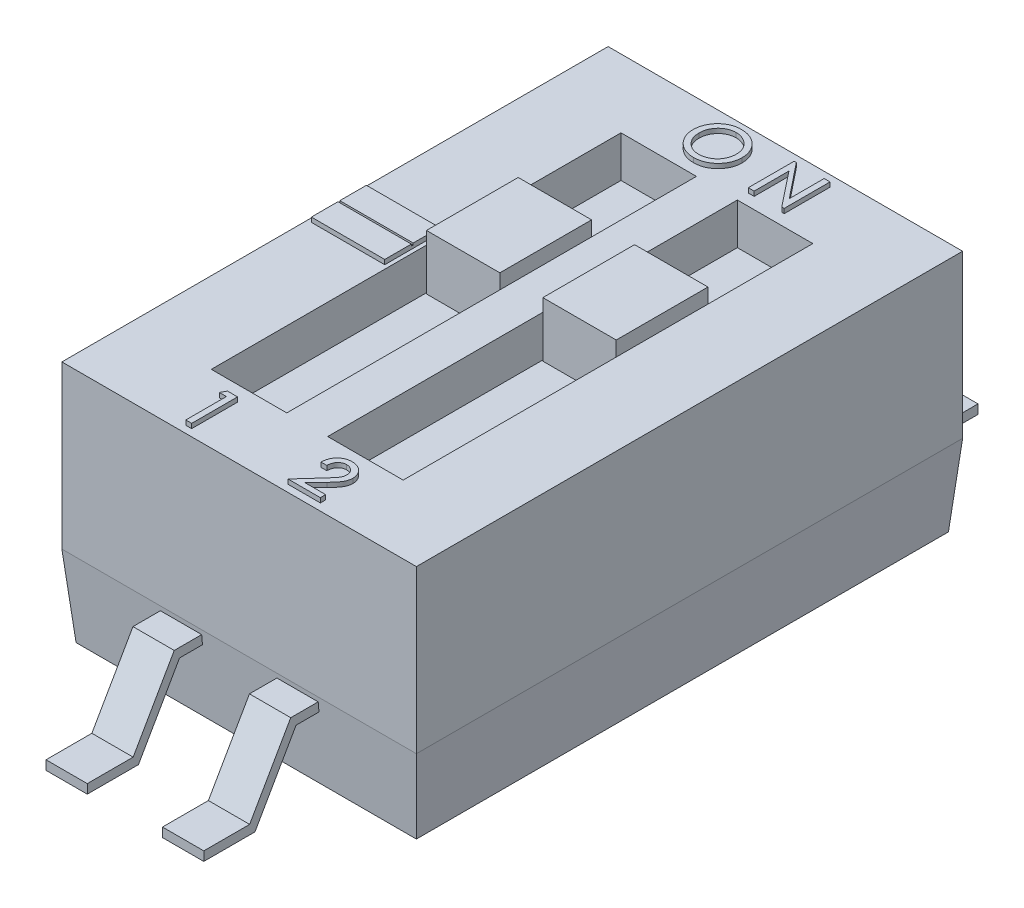
from build123d import *

# Parameters (mm, degrees)
SKETCH1_W            = 3.71
SKETCH1_H            = 5.8
BOSS_EXTRUDE1_DEPTH  = 0.883333333
BOSS_EXTRUDE1_TAPER  = -5
SKETCH2_W            = 3.864563306
SKETCH2_H            = 5.954563306
BOSS_EXTRUDE2_DEPTH  = 1.76666666
EXTRUDE_THIN1_START  = 1.3
EXTRUDE_THIN1_DEPTH  = 0.225
LPATTERN1_COUNT      = 2
LPATTERN1_PITCH      = 1.27
MIRROR1_START        = 1.3
MIRROR1_COPY_1_DEPTH = 0.225
SKETCH4_W            = 0.822718347
SKETCH4_H            = 4.46592248
CUT_EXTRUDE1_DEPTH   = 0.45
SKETCH7_W            = 0.8
SKETCH7_H            = 1
BOSS_EXTRUDE3_DEPTH  = 0.6
BOSS_EXTRUDE4_DEPTH  = 0.05
SKETCH10_W           = 0.803291247
SKETCH10_H           = 0.02
CUT_EXTRUDE2_DEPTH   = 0.02


with BuildPart() as part:
    # Sketch1 → Boss-Extrude1 (new body)
    with BuildSketch(Plane(origin=(0, 0, 0), x_dir=(1, 0, 0), z_dir=(0, 1, 0))):
        with Locations((1.855, 2.9)):
            Rectangle(SKETCH1_W, SKETCH1_H)
    extrude(amount=BOSS_EXTRUDE1_DEPTH, taper=BOSS_EXTRUDE1_TAPER)

    # Sketch2 → Boss-Extrude2 (add)
    with BuildSketch(Plane(origin=(0, 0.883333333, 0), x_dir=(1, 0, 0), z_dir=(0, 1, 0))):
        with Locations((1.855, 2.9)):
            Rectangle(SKETCH2_W, SKETCH2_H)
    extrude(amount=BOSS_EXTRUDE2_DEPTH)

    # Sketch3 → Extrude-Thin1 (add, symmetric)
    with BuildSketch(Plane(origin=(3.787281653, 2.093388662, 0), x_dir=(0, 0, -1), z_dir=(-1, 0, 0)).offset(EXTRUDE_THIN1_START)):
        Polygon((5.860743349, 1.260055329), (6.17213084, 1.260055329), (6.620020803, 2.043388662), (7.12, 2.043388662), (7.12, 2.143388662), (6.562005971, 2.143388662), (6.114116009, 1.360055329), (5.860743349, 1.360055329), align=None)
    extrude_thin1 = extrude(amount=EXTRUDE_THIN1_DEPTH, both=True)

    # LPattern1: Extrude-Thin1 ×2
    with Locations(*[(-i * LPATTERN1_PITCH, 0, 0) for i in range(1, LPATTERN1_COUNT)]):
        add(extrude_thin1)

    # Mirror1: Extrude-Thin1 across plane
    add(extrude_thin1.mirror(Plane.XY.offset(-2.9)))

    # Mirror1 copy 1 sketch → Mirror1 copy 1 (add, symmetric)
    with BuildSketch(Plane(origin=(2.517281653, 2.093388662, -5.8), x_dir=(0, 0, 1), z_dir=(-1, 0, 0)).offset(MIRROR1_START)):
        Polygon((5.860743349, -1.260055329), (6.17213084, -1.260055329), (6.620020803, -2.043388662), (7.12, -2.043388662), (7.12, -2.143388662), (6.562005971, -2.143388662), (6.114116009, -1.360055329), (5.860743349, -1.360055329), align=None)
    extrude(amount=MIRROR1_COPY_1_DEPTH, both=True)

    # Sketch4 → Cut-Extrude1 (cut)
    with BuildSketch(Plane(origin=(0, 2.649999993, 0), x_dir=(1, 0, 0), z_dir=(0, 1, 0))):
        with Locations((1.218640827, 2.9)):
            Rectangle(SKETCH4_W, SKETCH4_H)
        with Locations((2.487281653, 2.9)):
            Rectangle(SKETCH4_W, SKETCH4_H)
    extrude(amount=-CUT_EXTRUDE1_DEPTH, mode=Mode.SUBTRACT)

    # Sketch7 → Boss-Extrude3 (add)
    with BuildSketch(Plane(origin=(0, 2.199999993, 0), x_dir=(1, 0, 0), z_dir=(0, 1, 0))):
        with Locations((1.218640826, 3.501198468)):
            Rectangle(SKETCH7_W, SKETCH7_H)
        with Locations((2.487281653, 3.501198468)):
            Rectangle(SKETCH7_W, SKETCH7_H)
    extrude(amount=BOSS_EXTRUDE3_DEPTH)

    # Sketch9 → Boss-Extrude4 (add)
    with BuildSketch(Plane(origin=(0, 2.649999993, 0), x_dir=(1, 0, 0), z_dir=(0, 1, 0))):
        Polygon((0.365, 3.2), (-0.035, 3.2), (-0.035, 2.6), (0.765, 2.6), (0.765, 3.2), align=None)
        with BuildLine():
            add(Edge.make_bspline(
                [(1.479663964, 5.771654884), (1.489257845, 5.771433396), (1.508114811, 5.770998055), (1.535777861, 5.767286325), (1.562195202, 5.761348327), (1.587327869, 5.752866749), (1.611192828, 5.741999278), (1.633827731, 5.728725029), (1.655165361, 5.71300379), (1.674944838, 5.695037092), (1.692912044, 5.675465931), (1.708834839, 5.654777937), (1.722056925, 5.632881513), (1.733109928, 5.610093514), (1.741473317, 5.586202533), (1.747669692, 5.561410989), (1.75132416, 5.535552796), (1.75177232, 5.517960449), (1.751999701, 5.509034692)],
                knots=[0, 0, 0, 0, 2.8771e-05, 5.655e-05, 8.3569e-05, 0.00010989, 0.000135976, 0.000162104, 0.000188468, 0.000215344, 0.000242139, 0.000268081, 0.000293522, 0.000318743, 0.000343928, 0.000369314, 0.000395306, 0.000422076, 0.000422076, 0.000422076, 0.000422076], degree=3))
            add(Edge.make_bspline(
                [(1.751999701, 5.509034692), (1.751776692, 5.500174582), (1.751337183, 5.482712978), (1.747612498, 5.457012356), (1.741607695, 5.432250852), (1.733198418, 5.408380247), (1.722167038, 5.385582617), (1.708878823, 5.363666692), (1.693051826, 5.342841811), (1.675151667, 5.32313365), (1.655480601, 5.305102448), (1.634359091, 5.289267014), (1.612043342, 5.275938627), (1.588644525, 5.264843355), (1.563971225, 5.256513354), (1.538207672, 5.25033631), (1.511252453, 5.246686748), (1.492896153, 5.24624055), (1.483570214, 5.246013859)],
                knots=[0, 0, 0, 0, 2.657e-05, 5.2364e-05, 7.7726e-05, 0.00010291, 0.000128132, 0.000153572, 0.000179674, 0.000206476, 0.000233345, 0.000259607, 0.000285528, 0.000311202, 0.000337143, 0.000363502, 0.000390586, 0.000418557, 0.000418557, 0.000418557, 0.000418557], degree=3))
            add(Edge.make_bspline(
                [(1.483570214, 5.246013859), (1.474476052, 5.246233696), (1.456581448, 5.24666627), (1.430329778, 5.250413333), (1.405143496, 5.256254742), (1.381055145, 5.264649956), (1.358026463, 5.275357899), (1.336188652, 5.288640852), (1.315348755, 5.30411141), (1.295903175, 5.321834298), (1.278156443, 5.341241912), (1.262589861, 5.361900578), (1.249350395, 5.383547494), (1.238580322, 5.406207419), (1.23019009, 5.429901874), (1.224369717, 5.454625163), (1.220601755, 5.48030682), (1.220168337, 5.497769958), (1.219948419, 5.506630846)],
                knots=[0, 0, 0, 0, 2.727e-05, 5.3659e-05, 7.9387e-05, 0.000104728, 0.000130045, 0.000155433, 0.000181275, 0.000207794, 0.000234238, 0.00026006, 0.000285277, 0.000310231, 0.000335194, 0.000360532, 0.000386326, 0.000412896, 0.000412896, 0.000412896, 0.000412896], degree=3))
            add(Edge.make_bspline(
                [(1.219948419, 5.506630846), (1.220024725, 5.512578397), (1.220176375, 5.52439847), (1.222004794, 5.541950438), (1.224652588, 5.559222042), (1.228467221, 5.576155156), (1.23338749, 5.592752794), (1.239451934, 5.608980085), (1.246397915, 5.624974183), (1.254682806, 5.640417607), (1.263677877, 5.655400044), (1.273673358, 5.669519096), (1.284246363, 5.682946687), (1.295842055, 5.695324371), (1.30807273, 5.707015016), (1.321138279, 5.717838228), (1.334958582, 5.727891801), (1.349593212, 5.736951848), (1.364681536, 5.74514601), (1.380235362, 5.752177703), (1.396043443, 5.758212855), (1.412179821, 5.763104401), (1.428601646, 5.766966121), (1.445344758, 5.769595743), (1.462395819, 5.771427788), (1.47388315, 5.77157886), (1.479663964, 5.771654884)],
                knots=[0, 0, 0, 0, 1.7836e-05, 3.5446e-05, 5.2885e-05, 7.0234e-05, 8.7474e-05, 0.000104777, 0.000122178, 0.000139741, 0.000157314, 0.00017457, 0.000191605, 0.000208544, 0.000225405, 0.000242333, 0.000259403, 0.000276634, 0.000293932, 0.000310876, 0.000327804, 0.00034466, 0.000361424, 0.000378368, 0.00039548, 0.000412815, 0.000412815, 0.000412815, 0.000412815], degree=3))
        make_face()
        with BuildLine():
            add(Edge.make_bspline(
                [(1.481767329, 5.713962577), (1.477556873, 5.713895927), (1.469182182, 5.71376336), (1.456706127, 5.712375722), (1.444359264, 5.710291289), (1.432120207, 5.707359756), (1.419978865, 5.703696746), (1.40803974, 5.699010727), (1.396187477, 5.693649112), (1.384633487, 5.687293585), (1.373370275, 5.680394675), (1.362716929, 5.672692959), (1.352551182, 5.664506348), (1.343019529, 5.655559036), (1.334139864, 5.645968161), (1.325862878, 5.635749499), (1.318125396, 5.624938392), (1.311096856, 5.613459905), (1.304605208, 5.601551603), (1.299140706, 5.589136394), (1.294511867, 5.576346372), (1.29071283, 5.563195005), (1.287669032, 5.549656276), (1.285632562, 5.535725166), (1.284240524, 5.521416076), (1.284114809, 5.511742461), (1.284050983, 5.506831166)],
                knots=[0, 0, 0, 0, 1.2627e-05, 2.5114e-05, 3.7612e-05, 5.0172e-05, 6.2846e-05, 7.5624e-05, 8.8622e-05, 0.000101844, 0.000115157, 0.000128221, 0.000141252, 0.00015429, 0.000167402, 0.000180433, 0.000193718, 0.000207255, 0.000220788, 0.000234375, 0.000247904, 0.000261566, 0.000275417, 0.000289498, 0.00030378, 0.000318509, 0.000318509, 0.000318509, 0.000318509], degree=3))
            add(Edge.make_bspline(
                [(1.284050983, 5.506831166), (1.284206025, 5.499676188), (1.284510118, 5.485642709), (1.287442798, 5.465058319), (1.29198946, 5.445388442), (1.298425049, 5.426652988), (1.306711554, 5.408857624), (1.316853606, 5.392007493), (1.328868208, 5.37606037), (1.342612023, 5.361322703), (1.357511695, 5.347856567), (1.373315803, 5.336122329), (1.38966252, 5.325975478), (1.406814183, 5.317842465), (1.424602673, 5.31150428), (1.443058189, 5.306994222), (1.46218414, 5.304205711), (1.47518063, 5.303874186), (1.481767329, 5.303706166)],
                knots=[0, 0, 0, 0, 2.1453e-05, 4.2078e-05, 6.2242e-05, 8.1944e-05, 0.000101392, 0.000121025, 0.000140837, 0.000161179, 0.000181391, 0.000201003, 0.000220157, 0.000239018, 0.000257836, 0.000276711, 0.000295933, 0.000315685, 0.000315685, 0.000315685, 0.000315685], degree=3))
            add(Edge.make_bspline(
                [(1.481767329, 5.303706166), (1.486444689, 5.303772991), (1.495717864, 5.303905476), (1.509464321, 5.305273757), (1.522938786, 5.307383462), (1.536149198, 5.310223478), (1.549056227, 5.314140428), (1.561757274, 5.318646628), (1.574112924, 5.32426634), (1.586211938, 5.330483365), (1.597745439, 5.337633265), (1.608843407, 5.345234101), (1.619281571, 5.353504438), (1.628859728, 5.362609623), (1.63796836, 5.372137191), (1.646360232, 5.382354468), (1.65409403, 5.393194753), (1.661092183, 5.404623331), (1.667369268, 5.416503304), (1.672948509, 5.428746562), (1.677483268, 5.441371165), (1.681374554, 5.454253628), (1.684243628, 5.467525424), (1.686318189, 5.481106256), (1.68770315, 5.495017115), (1.687831948, 5.504390585), (1.687897137, 5.509134852)],
                knots=[0, 0, 0, 0, 1.4028e-05, 2.7812e-05, 4.1397e-05, 5.4934e-05, 6.8307e-05, 8.1836e-05, 9.5331e-05, 0.000108995, 0.000122617, 0.000136009, 0.000149336, 0.000162516, 0.000175623, 0.000188858, 0.000202143, 0.000215542, 0.000229029, 0.000242433, 0.000255868, 0.000269241, 0.000282778, 0.000296561, 0.000310444, 0.000324673, 0.000324673, 0.000324673, 0.000324673], degree=3))
            add(Edge.make_bspline(
                [(1.687897137, 5.509134852), (1.687831649, 5.513845725), (1.687702271, 5.523152541), (1.686325146, 5.536931023), (1.684246059, 5.550345649), (1.681356813, 5.563445081), (1.677502968, 5.576171928), (1.672944873, 5.588623597), (1.667368986, 5.60066762), (1.66108834, 5.612345411), (1.654076582, 5.623622283), (1.646253066, 5.634286692), (1.637832783, 5.644461976), (1.628691014, 5.653998205), (1.618821731, 5.662930127), (1.608318659, 5.671324642), (1.597150185, 5.6792141), (1.585288698, 5.686319083), (1.573050942, 5.692847367), (1.560502018, 5.698414613), (1.547858959, 5.703287053), (1.535005191, 5.707201381), (1.52194315, 5.710185957), (1.508705267, 5.712412671), (1.495283488, 5.713751208), (1.486277503, 5.713892045), (1.481767329, 5.713962577)],
                knots=[0, 0, 0, 0, 1.4128e-05, 2.7912e-05, 4.1497e-05, 5.4838e-05, 6.8116e-05, 8.1363e-05, 9.4584e-05, 0.000107894, 0.000121122, 0.000134385, 0.000147543, 0.000160719, 0.000173978, 0.000187446, 0.000201035, 0.000214966, 0.0002289, 0.000242619, 0.000256124, 0.000269526, 0.000282889, 0.000296293, 0.000309777, 0.000323305, 0.000323305, 0.000323305, 0.000323305], degree=3))
        make_face(mode=Mode.SUBTRACT)
        Polygon((2.069307393, 5.258834372), (2.069307393, 5.758834372), (2.093045374, 5.758834372), (2.39623047, 5.378926519), (2.39623047, 5.758834372), (2.460333034, 5.758834372), (2.460333034, 5.258834372), (2.434091047, 5.258834372), (2.133409958, 5.637740622), (2.133409958, 5.258834372), align=None)
        Polygon((1.151533455, 0.5), (1.260307493, 0.5), (1.260307493, 0), (1.196204929, 0), (1.196204929, 0.442307692), (1.119281852, 0.442307692), align=None)
        with BuildLine():
            Line((2.393631813, 0.33974359), (2.330230371, 0.33974359))
            add(Edge.make_bspline(
                [(2.330230371, 0.33974359), (2.330528186, 0.346195027), (2.331110673, 0.358813154), (2.333697214, 0.377199175), (2.337887225, 0.394523497), (2.343175904, 0.410932983), (2.350230855, 0.426222507), (2.358370857, 0.440658605), (2.368197709, 0.453938723), (2.379302589, 0.46608387), (2.391357329, 0.477118209), (2.40431623, 0.48663291), (2.417960248, 0.49474084), (2.432292066, 0.501356964), (2.447339751, 0.506479703), (2.46306041, 0.510207392), (2.479504196, 0.512449508), (2.490713508, 0.512695701), (2.496396236, 0.512820513)],
                knots=[0, 0, 0, 0, 1.9368e-05, 3.7882e-05, 5.5592e-05, 7.2791e-05, 8.951e-05, 0.000106021, 0.000122428, 0.000138948, 0.000155327, 0.000171373, 0.000187091, 0.000202866, 0.00021864, 0.000234698, 0.000251272, 0.000268313, 0.000268313, 0.000268313, 0.000268313], degree=3))
            add(Edge.make_bspline(
                [(2.496396236, 0.512820513), (2.502346064, 0.512698805), (2.514021273, 0.512459981), (2.531023188, 0.510212616), (2.547113945, 0.506588742), (2.562298254, 0.501639833), (2.576548451, 0.49503175), (2.589892637, 0.487063131), (2.60220254, 0.477485139), (2.613567505, 0.466767963), (2.623605708, 0.454978982), (2.632672267, 0.442858509), (2.640166656, 0.430160727), (2.646445064, 0.417117501), (2.651276399, 0.403621779), (2.654688272, 0.389728483), (2.656733406, 0.375428172), (2.657012545, 0.365758451), (2.657153448, 0.360877404)],
                knots=[0, 0, 0, 0, 1.7842e-05, 3.5012e-05, 5.134e-05, 6.7272e-05, 8.2823e-05, 9.8368e-05, 0.000113794, 0.000129523, 0.000145145, 0.00016019, 0.000174877, 0.000189303, 0.000203559, 0.000217795, 0.000232158, 0.000246798, 0.000246798, 0.000246798, 0.000246798], degree=3))
            add(Edge.make_bspline(
                [(2.657153448, 0.360877404), (2.656897047, 0.35404962), (2.656387759, 0.340487589), (2.65246608, 0.320423342), (2.64587328, 0.30100534), (2.638257964, 0.285193993), (2.630555991, 0.272413457), (2.623487943, 0.261864272), (2.615184815, 0.2504574), (2.605468543, 0.238269201), (2.594725485, 0.225020803), (2.582528884, 0.211053973), (2.569256244, 0.196085945), (2.559790404, 0.186007166), (2.554889826, 0.180789263)],
                knots=[0, 0, 0, 0, 2.0474e-05, 4.0668e-05, 6.1066e-05, 8.1852e-05, 9.3172e-05, 0.000105811, 0.000119935, 0.000135485, 0.000152567, 0.000171101, 0.000191106, 0.000212579, 0.000212579, 0.000212579, 0.000212579], degree=3))
            Line((2.554889826, 0.180789263), (2.431893031, 0.057692308))
            Line((2.431893031, 0.057692308), (2.663563704, 0.057692308))
            Line((2.663563704, 0.057692308), (2.663563704, 0))
            Line((2.663563704, 0), (2.310999601, 0))
            Line((2.310999601, 0), (2.502305691, 0.211237981))
            add(Edge.make_bspline(
                [(2.502305691, 0.211237981), (2.506862349, 0.216097605), (2.515606658, 0.225423312), (2.527930523, 0.239074651), (2.539049409, 0.2516951), (2.549022594, 0.26327555), (2.557588921, 0.273971653), (2.564978841, 0.283626052), (2.571108699, 0.292284336), (2.577474587, 0.302475857), (2.583782528, 0.31469272), (2.58914858, 0.329595576), (2.592368474, 0.344814626), (2.592823302, 0.355053224), (2.593050884, 0.360176282)],
                knots=[0, 0, 0, 0, 1.9985e-05, 3.8351e-05, 5.517e-05, 7.0445e-05, 8.4195e-05, 9.6274e-05, 0.000106917, 0.000116005, 0.00013231, 0.000148056, 0.000163397, 0.000178761, 0.000178761, 0.000178761, 0.000178761], degree=3))
            add(Edge.make_bspline(
                [(2.593050884, 0.360176282), (2.592994798, 0.363354433), (2.592883821, 0.369643049), (2.591370836, 0.378851972), (2.589239526, 0.387784115), (2.585943133, 0.396295876), (2.581971587, 0.404554714), (2.577003889, 0.412453867), (2.571038568, 0.419920061), (2.564402709, 0.42712128), (2.557063274, 0.433623165), (2.549311077, 0.439454405), (2.541050785, 0.44419013), (2.532508246, 0.448331605), (2.52341791, 0.45126764), (2.514003229, 0.453453669), (2.504190278, 0.454967975), (2.497503834, 0.455074075), (2.49409255, 0.455128205)],
                knots=[0, 0, 0, 0, 9.524e-06, 1.8844e-05, 2.793e-05, 3.7027e-05, 4.6165e-05, 5.5391e-05, 6.4949e-05, 7.48e-05, 8.4731e-05, 9.4327e-05, 0.000103844, 0.000113253, 0.000122755, 0.000132425, 0.000142241, 0.000152465, 0.000152465, 0.000152465, 0.000152465], degree=3))
            add(Edge.make_bspline(
                [(2.49409255, 0.455128205), (2.49084946, 0.455061689), (2.484469451, 0.454930834), (2.475073308, 0.453580711), (2.466054174, 0.451382445), (2.457381624, 0.448333251), (2.448992844, 0.444571427), (2.441092953, 0.439697992), (2.43355283, 0.434028686), (2.426272793, 0.427665742), (2.41964712, 0.420200743), (2.413720948, 0.41172215), (2.408487904, 0.402220724), (2.404014937, 0.391713087), (2.40030797, 0.380171672), (2.397334255, 0.367610514), (2.395035285, 0.354024144), (2.394108292, 0.344591834), (2.393631813, 0.33974359)],
                knots=[0, 0, 0, 0, 9.724e-06, 1.9129e-05, 2.8409e-05, 3.7532e-05, 4.6675e-05, 5.5934e-05, 6.5309e-05, 7.4958e-05, 8.4889e-05, 9.5171e-05, 0.00010593, 0.000117372, 0.000129377, 0.000142252, 0.000156068, 0.000170679, 0.000170679, 0.000170679, 0.000170679], degree=3))
        make_face()
    extrude(amount=BOSS_EXTRUDE4_DEPTH)

    # Sketch10 → Cut-Extrude2 (cut)
    with BuildSketch(Plane(origin=(0, 2.699999993, 0), x_dir=(1, 0, 0), z_dir=(0, 1, 0))):
        with Locations((0.365138907, 2.9)):
            Rectangle(SKETCH10_W, SKETCH10_H)
    extrude(amount=-CUT_EXTRUDE2_DEPTH, mode=Mode.SUBTRACT)


solid = part.part
